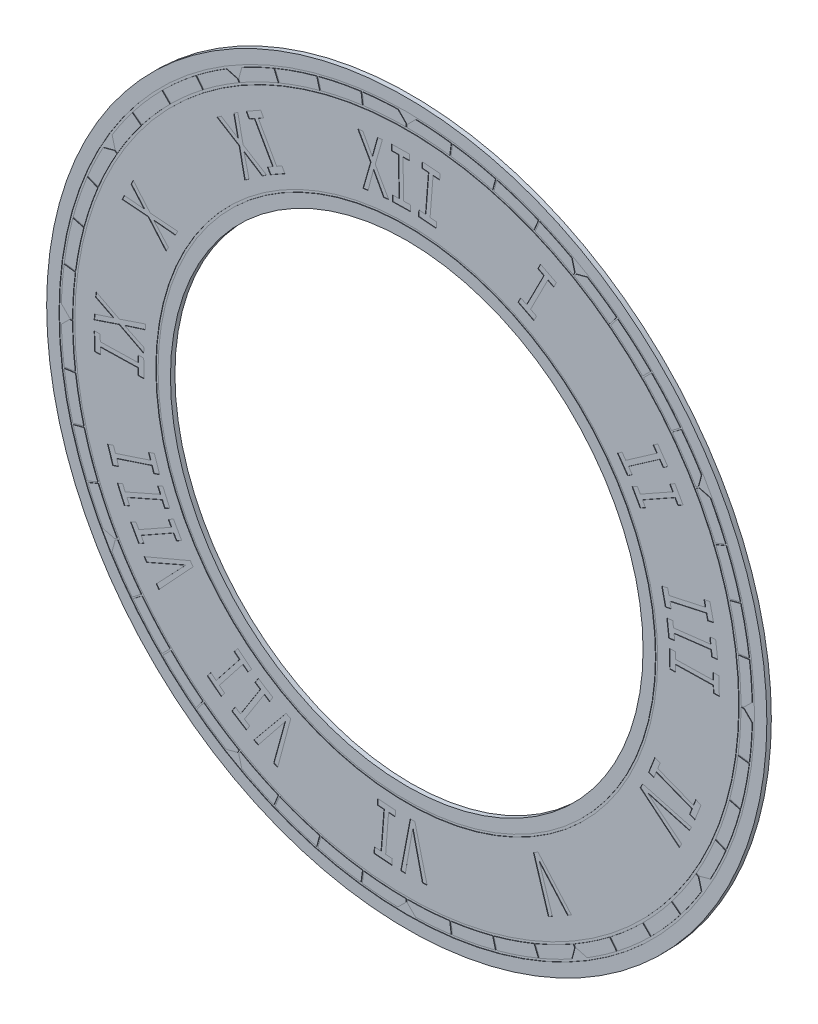
from build123d import *

# Parameters (mm, degrees)
SKETCH1_R               = 80
SKETCH1_R_2             = 52.5
BOSS_EXTRUDE1_DEPTH     = 1
SKETCH2_R               = 77.25
SKETCH2_R_2             = 76.75
SKETCH2_R_3             = 74.25
SKETCH2_R_4             = 73.75
SKETCH2_R_5             = 55.75
SKETCH2_R_6             = 55.25
CUT_EXTRUDE_THIN2_DEPTH = 0.1
CUT_EXTRUDE_THIN5_START = -0.1
SKETCH5_W               = 0.3
SKETCH5_H               = 3
CUT_EXTRUDE_THIN5_DEPTH = 114.241504321
CIRPATTERN2_COUNT       = 48
CUT_EXTRUDE1_DEPTH      = 0.1
CIRPATTERN1_COUNT       = 12
CUT_EXTRUDE5_DEPTH      = 0.1


with BuildPart() as part:
    # Sketch1 → Boss-Extrude1 (new body)
    with BuildSketch(Plane.XY):
        Circle(SKETCH1_R)
        Circle(SKETCH1_R_2, mode=Mode.SUBTRACT)
    extrude(amount=BOSS_EXTRUDE1_DEPTH)

    # Sketch2 → Cut-Extrude-Thin2 (cut)
    with BuildSketch(Plane.XY.offset(1)):
        Circle(SKETCH2_R)
        Circle(SKETCH2_R_2, mode=Mode.SUBTRACT)
        Circle(SKETCH2_R_3)
        Circle(SKETCH2_R_4, mode=Mode.SUBTRACT)
        Circle(SKETCH2_R_5)
        Circle(SKETCH2_R_6, mode=Mode.SUBTRACT)
    extrude(amount=-CUT_EXTRUDE_THIN2_DEPTH, mode=Mode.SUBTRACT)

    # Sketch5 → Cut-Extrude-Thin5 (cut)
    with BuildSketch(Plane.XY.offset(1).offset(CUT_EXTRUDE_THIN5_START)):
        with Locations((0, 75.5)):
            Rectangle(SKETCH5_W, SKETCH5_H)
    cut_extrude_thin5 = extrude(amount=CUT_EXTRUDE_THIN5_DEPTH, mode=Mode.SUBTRACT)

    # CirPattern2: Cut-Extrude-Thin5 ×48 about axis
    cirpattern2_axis = Axis((0, 0, 0), (0, 0, 1))
    for i in range(1, CIRPATTERN2_COUNT):
        add(cut_extrude_thin5.rotate(cirpattern2_axis, i * 360 / CIRPATTERN2_COUNT), mode=Mode.SUBTRACT)

    # Sketch3 → Cut-Extrude1 (cut)
    with BuildSketch(Plane.XY.offset(1)):
        Polygon((-2, 76.75), (2, 76.75), (0, 74.75), align=None)
    cut_extrude1 = extrude(amount=-CUT_EXTRUDE1_DEPTH, mode=Mode.SUBTRACT)

    # CirPattern1: Cut-Extrude1 ×12 about axis
    cirpattern1_axis = Axis((0, 0, 0), (0, 0, 1))
    for i in range(1, CIRPATTERN1_COUNT):
        add(cut_extrude1.rotate(cirpattern1_axis, i * 360 / CIRPATTERN1_COUNT), mode=Mode.SUBTRACT)

    # Sketch6 → Cut-Extrude5 (cut)
    with BuildSketch(Plane.XY.offset(1)):
        Polygon((-9.718418394, 57.663961885), (-8.047793394, 63.500836885), (-10.887168394, 68.531045218), (-9.757376727, 68.666253551), (-7.660501727, 64.846045218), (-6.49633506, 69.055836885), (-5.407793394, 69.184170218), (-6.995918394, 63.642920218), (-3.998418394, 58.344586885), (-5.137376727, 58.209378551), (-7.40383506, 62.387086885), (-8.588626727, 57.799170218), align=None)
        Polygon((-1.705759128, 59.70189458), (-1.866175795, 68.06189458), (-3.332842462, 68.03439458), (-3.358050795, 69.35439458), (0.601949205, 69.43001958), (0.627157538, 68.11001958), (-0.839509128, 68.08251958), (-0.679092462, 59.72251958), (0.787574205, 59.75001958), (0.812782538, 58.43001958), (-3.147217462, 58.35439458), (-3.172425795, 59.67439458), align=None)
        Polygon((4.157245471, 59.586268139), (4.814953804, 67.946268139), (3.348287138, 68.063143139), (3.453703804, 69.383143139), (7.413703804, 69.069184806), (7.308287138, 67.749184806), (5.841620471, 67.866059806), (5.183912138, 59.506059806), (6.650578804, 59.389184806), (6.547453804, 58.069184806), (2.587453804, 58.383143139), (2.690578804, 59.703143139), align=None)
        Polygon((26.62958426, 53.459390486), (30.442917594, 60.939390486), (29.122917594, 61.610848819), (29.721042594, 62.784182152), (33.241042594, 60.989807152), (32.642917594, 59.816473819), (31.322917594, 60.490223819), (27.50958426, 53.010223819), (28.82958426, 52.336473819), (28.23145926, 51.163140486), (24.71145926, 52.957515486), (25.30958426, 54.130848819), align=None)
        Polygon((48.65739433, 34.519733211), (55.550727664, 39.327649877), (54.732602664, 40.500983211), (55.75926933, 41.215983211), (58.009685997, 37.989316544), (56.98301933, 37.274316544), (56.16489433, 38.447649877), (49.271560997, 33.639733211), (50.089685997, 32.466399877), (49.06301933, 31.749108211), (46.812602664, 34.975774877), (47.83926933, 35.693066544), align=None)
        Polygon((51.887970001, 29.633997783), (59.074636667, 33.667331116), (58.414636667, 34.84066445), (59.587970001, 35.50066445), (61.398386667, 32.273997783), (60.225053334, 31.613997783), (59.567345001, 32.787331116), (52.380678334, 28.753997783), (53.038386667, 27.58066445), (51.865053334, 26.922956116), (50.054636667, 30.149622783), (51.227970001, 30.807331116), align=None)
        Polygon((58.255299718, 13.313291091), (66.321966385, 15.087041091), (66.033216385, 16.407041091), (67.353216385, 16.695791091), (68.157591385, 13.029124425), (66.837591385, 12.740374425), (66.548841385, 14.060374425), (58.482174718, 12.286624425), (58.770924718, 10.966624425), (57.450924718, 10.675582758), (56.646549718, 14.342249425), (57.966549718, 14.633291091), align=None)
        Polygon((59.253523834, 7.586547801), (67.466857167, 8.565089467), (67.308732167, 9.885089467), (68.628732167, 10.043214467), (69.0664405, 6.376547801), (67.7464405, 6.218422801), (67.5883155, 7.538422801), (59.374982167, 6.559881134), (59.533107167, 5.239881134), (58.213107167, 5.081756134), (57.775398834, 8.748422801), (59.095398834, 8.906547801), align=None)
        Polygon((59.702227739, 1.76320353), (68.062227739, 1.937370197), (68.032436072, 3.404036863), (69.352436072, 3.431536863), (69.434936072, -0.528463137), (68.114936072, -0.555963137), (68.085144405, 0.91070353), (59.725144405, 0.736536863), (59.754936072, -0.730129803), (58.434936072, -0.757629803), (58.352436072, 3.202370197), (59.672436072, 3.229870197), align=None)
        Polygon((55.763282271, -21.230822241), (63.683282271, -24.317697241), (64.196615604, -22.997697241), (65.369948938, -23.456030574), (63.997240604, -26.976030574), (62.823907271, -26.517697241), (63.339532271, -25.197697241), (55.419532271, -22.110822241), (54.903907271, -23.430822241), (53.730573938, -22.972488907), (55.103282271, -19.452488907), (56.276615604, -19.910822241), align=None)
        Polygon((61.057451041, -33.098040061), (60.573909374, -34.051373394), (51.863284374, -26.866998394), (52.383492708, -25.840331728), (63.252867708, -28.771373394), (62.810576041, -29.644498394), (53.595784374, -27.098456728), align=None)
        Polygon((32.347351242, -61.377435954), (31.458184575, -61.879310954), (28.139851242, -51.188685954), (29.166517909, -50.608894288), (36.591517909, -58.984935954), (35.718392909, -59.477644288), (29.459851242, -52.325352621), align=None)
        Polygon((-0.316907685, -69.4372838), (-1.332116018, -69.460200466), (0.767050649, -58.407492133), (1.793717315, -58.3822838), (4.534550649, -69.3272838), (3.475800649, -69.350200466), (1.319342315, -60.0391588), align=None)
        Polygon((-4.041328783, -59.595495082), (-4.685287117, -67.955495082), (-3.21862045, -68.067786749), (-3.319453783, -69.387786749), (-7.279453783, -69.082995082), (-7.17862045, -67.762995082), (-5.711953783, -67.875286749), (-5.06799545, -59.515286749), (-6.534662117, -59.402995082), (-6.433828783, -58.082995082), (-2.473828783, -58.387786749), (-2.574662117, -59.707786749), align=None)
        Polygon((-33.019192679, -61.094403228), (-33.972526013, -60.610861561), (-26.808776013, -51.895653228), (-25.782109346, -52.415861561), (-28.692526013, -63.278361561), (-29.565651013, -62.838361561), (-27.035651013, -53.628153228), align=None)
        Polygon((-31.666475868, -50.726687042), (-36.057309202, -57.620020375), (-34.883975868, -58.367103708), (-35.631059202, -59.540437042), (-38.857725868, -57.484812042), (-38.110642535, -56.311478708), (-36.937309202, -57.058562042), (-32.546475868, -50.165228708), (-33.719809202, -49.418145375), (-32.972725868, -48.244812042), (-29.746059202, -50.300437042), (-30.493142535, -51.473770375), align=None)
        Polygon((-36.439877018, -47.306637436), (-41.616752018, -53.906637436), (-40.443418685, -54.825595769), (-41.247793685, -55.852262436), (-44.327793685, -53.439137436), (-43.523418685, -52.412470769), (-42.350085352, -53.331429103), (-37.173210352, -46.731429103), (-38.346543685, -45.812470769), (-37.542168685, -44.785804103), (-34.462168685, -47.198929103), (-35.266543685, -48.225595769), align=None)
        Polygon((-57.784191683, -38.341316318), (-58.361691683, -37.516316318), (-48.081275016, -33.157566318), (-47.464816683, -34.037566318), (-55.077733349, -42.209649651), (-55.643775016, -41.400691318), (-49.110233349, -34.537149651), align=None)
        Polygon((-51.832261353, -29.730570927), (-59.01892802, -33.779945927), (-58.35892802, -34.95327926), (-59.532261353, -35.615570927), (-61.34955302, -32.38890426), (-60.176219686, -31.726612593), (-59.516219686, -32.899945927), (-52.32955302, -28.850570927), (-52.98955302, -27.677237593), (-51.816219686, -27.017237593), (-49.99892802, -30.24390426), (-51.172261353, -30.90390426), align=None)
        Polygon((-54.382884604, -24.611133812), (-62.156217937, -28.039467146), (-61.574134604, -29.359467146), (-62.747467937, -29.875092146), (-64.298926271, -26.355092146), (-63.125592937, -25.839467146), (-62.543509604, -27.159467146), (-54.770176271, -23.731133812), (-55.352259604, -22.411133812), (-54.178926271, -21.893217146), (-52.627467937, -25.413217146), (-53.800801271, -25.931133812), align=None)
        Polygon((-56.652066077, -19.14668463), (-64.42539941, -21.70418463), (-63.989982743, -23.02418463), (-65.309982743, -23.45730963), (-66.469566077, -19.93730963), (-65.149566077, -19.50418463), (-64.71414941, -20.82418463), (-56.940816077, -18.26668463), (-57.376232743, -16.94668463), (-56.056232743, -16.51355963), (-54.89664941, -20.03355963), (-56.21664941, -20.46668463), align=None)
        Polygon((-59.698053965, -1.877051081), (-68.058053965, -2.064967748), (-68.025970632, -3.531634414), (-69.345970632, -3.561426081), (-69.435345632, 0.398573919), (-68.115345632, 0.428365586), (-68.083262298, -1.038301081), (-59.723262298, -0.850384414), (-59.755345632, 0.616282252), (-58.435345632, 0.646073919), (-58.345970632, -3.313926081), (-59.665970632, -3.343717748), align=None)
        Polygon((-58.457554727, 1.541017517), (-63.911721394, 4.35747585), (-69.446096394, 2.496642517), (-69.35901306, 3.65622585), (-65.169846394, 5.008309184), (-69.109221394, 7.002059184), (-69.024429727, 8.115809184), (-63.847554727, 5.439142517), (-58.01526306, 7.407684184), (-58.10463806, 6.238934184), (-62.68338806, 4.78372585), (-58.370471394, 2.698309184), align=None)
        Polygon((-53.472073626, 23.682111233), (-57.450406959, 28.3181529), (-63.243740292, 28.7581529), (-62.730406959, 29.771069566), (-58.364781959, 29.3906529), (-61.252281959, 32.699819566), (-60.759573626, 33.676069566), (-56.985198626, 29.2737779), (-50.880198626, 28.815444566), (-51.395823626, 27.793361233), (-56.157906959, 28.233361233), (-52.961031959, 24.6950279), align=None)
        Polygon((-35.984278941, 46.099439556), (-37.233237275, 52.069231223), (-42.164903941, 55.121731223), (-41.209278941, 55.793189556), (-37.517403941, 53.448814556), (-38.450112275, 57.734231223), (-37.531153941, 58.378189556), (-36.346362275, 52.708606223), (-31.144278941, 49.502564556), (-32.109070608, 48.824231223), (-36.126362275, 51.402356223), (-35.028653941, 46.77089789), align=None)
        Polygon((-29.778860833, 51.808808498), (-33.844277499, 58.995475165), (-35.017610833, 58.333183498), (-35.679902499, 59.506516832), (-32.453235833, 61.330683498), (-31.790944166, 60.157350165), (-32.964277499, 59.495058498), (-28.898860833, 52.308391832), (-27.725527499, 52.970683498), (-27.060944166, 51.797350165), (-30.287610833, 49.973183498), (-30.952194166, 51.146516832), align=None)
    extrude(amount=-CUT_EXTRUDE5_DEPTH, mode=Mode.SUBTRACT)


solid = part.part
